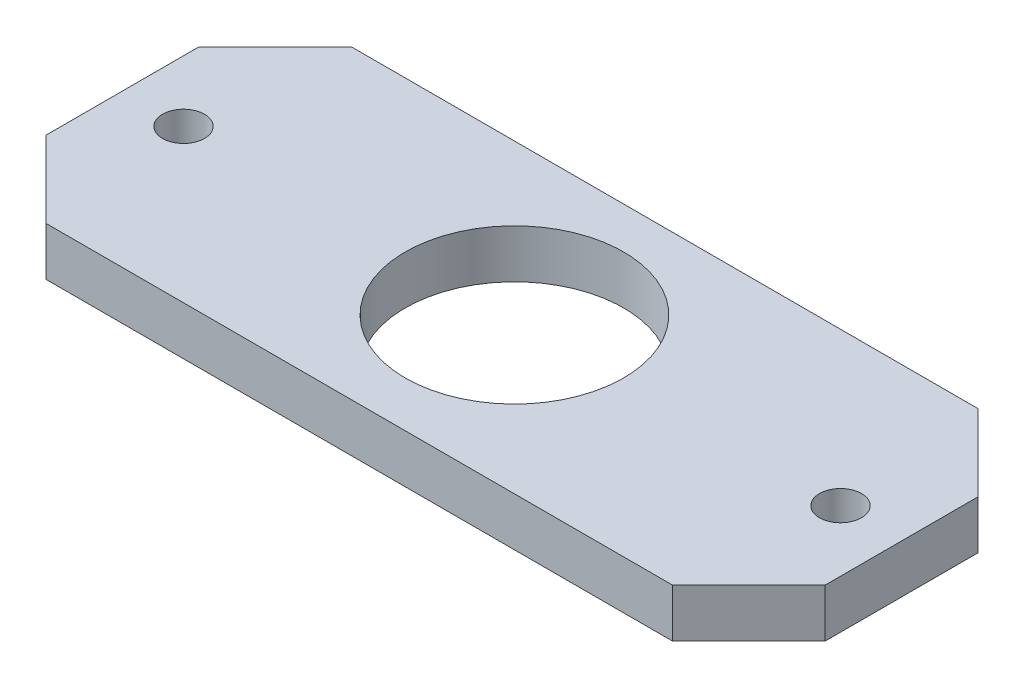
from build123d import *

# Parameters (mm, degrees)
SKETCH1_W           = 82
SKETCH1_H           = 70
BOSS_EXTRUDE1_DEPTH = 6.35
SKETCH4_R           = 14.295
CUT_EXTRUDE3_DEPTH  = 7.35
SKETCH7_W           = 70
SKETCH7_H           = 6.35
BOSS_EXTRUDE2_DEPTH = 10
SKETCH8_W           = 70
SKETCH8_H           = 6.35
BOSS_EXTRUDE3_DEPTH = 10
SKETCH6_R           = 2.75
CUT_EXTRUDE4_DEPTH  = 10
CHAMFER1_SIZE       = 25
SKETCH9_OUTSIDE_W   = 128.774
SKETCH9_OUTSIDE_H   = 96.774
SKETCH9_OUTSIDE_W_2 = 112.086128576
SKETCH9_OUTSIDE_H_2 = 40
CUT_EXTRUDE6_DEPTH  = 6.35


with BuildPart() as part:
    # Sketch1 → Boss-Extrude1 (new body)
    with BuildSketch(Plane(origin=(0, 0, 0), x_dir=(1, 0, 0), z_dir=(0, 1, 0))):
        with Locations((40.204600864, 28.763107794)):
            Rectangle(SKETCH1_W, SKETCH1_H)
    extrude(amount=BOSS_EXTRUDE1_DEPTH)

    # Sketch4 → Cut-Extrude3 (cut, through all)
    with BuildSketch(Plane(origin=(0, 6.35, 0), x_dir=(1, 0, 0), z_dir=(0, 1, 0))):
        with Locations((40.245025705, 29.040694999)):
            Circle(SKETCH4_R)
    extrude(amount=-CUT_EXTRUDE3_DEPTH, mode=Mode.SUBTRACT)

    # Sketch7 → Boss-Extrude2 (add)
    with BuildSketch(Plane.ZY.offset(0.795399136)):
        with Locations((-28.763107794, 3.175)):
            Rectangle(SKETCH7_W, SKETCH7_H)
    extrude(amount=BOSS_EXTRUDE2_DEPTH)

    # Sketch8 → Boss-Extrude3 (add)
    with BuildSketch(Plane(origin=(81.204600864, 0, 0), x_dir=(0, 0, -1), z_dir=(1, 0, 0))):
        with Locations((28.763107794, 3.175)):
            Rectangle(SKETCH8_W, SKETCH8_H)
    extrude(amount=BOSS_EXTRUDE3_DEPTH)

    # Sketch6 → Cut-Extrude4 (cut)
    with BuildSketch(Plane.XZ):
        with Locations((-2.795399136, -28.763107793)):
            Circle(SKETCH6_R)
        with Locations((83.204600864, -28.763107784)):
            Circle(SKETCH6_R)
    extrude(amount=-CUT_EXTRUDE4_DEPTH, mode=Mode.SUBTRACT)

    # Chamfer1
    chamfer1_edges = [part.edges().sort_by_distance(p)[0] for p in [
        (-10.795399136, 3.175, 6.236892206),
        (-10.795399136, 3.175, -63.763107794),
        (91.204600864, 3.175, 6.236892206),
        (91.204600864, 3.175, -63.763107794),
    ]]
    chamfer(chamfer1_edges, length=CHAMFER1_SIZE)

    # Sketch9 outside → Cut-Extrude6 (cut)
    with BuildSketch(Plane.XZ):
        with Locations((40.205, -28.763)):
            Rectangle(SKETCH9_OUTSIDE_W, SKETCH9_OUTSIDE_H)
        with Locations((41.847145894, -28.763107784)):
            Rectangle(SKETCH9_OUTSIDE_W_2, SKETCH9_OUTSIDE_H_2, mode=Mode.SUBTRACT)
    extrude(amount=-CUT_EXTRUDE6_DEPTH, mode=Mode.SUBTRACT)


solid = part.part
